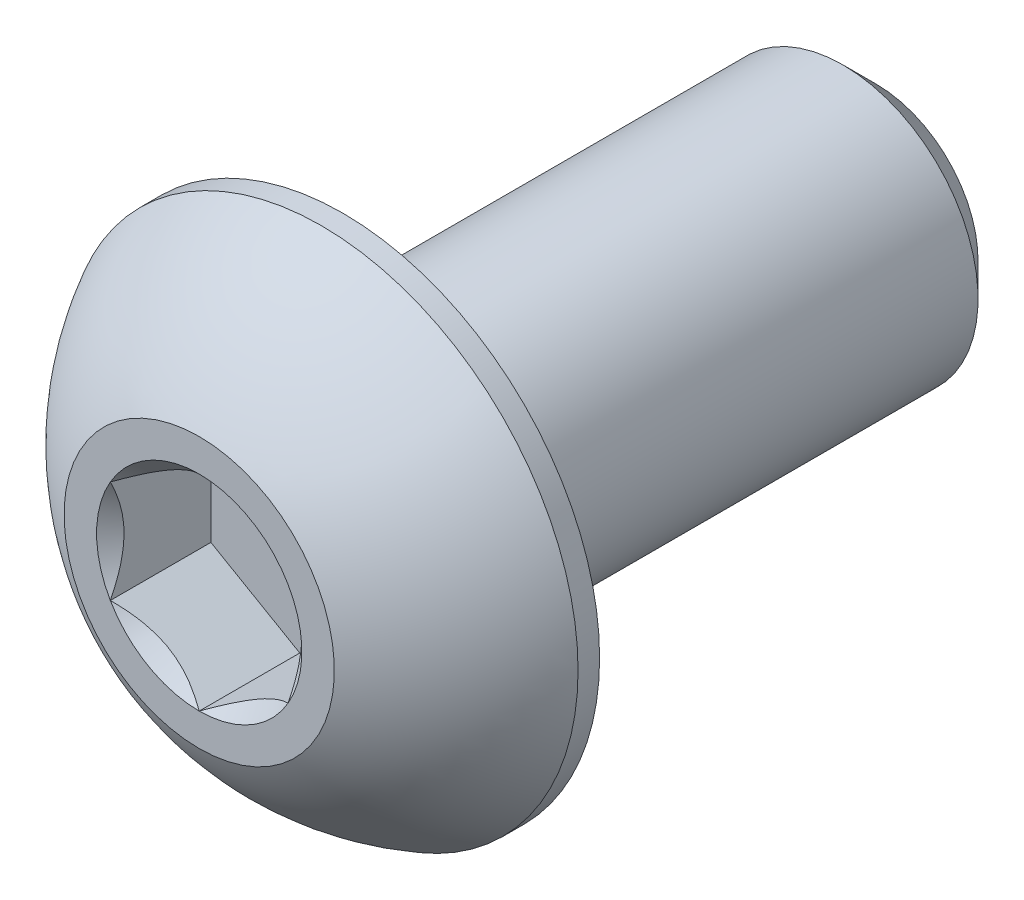
from build123d import *

# Parameters (mm, degrees)
SKETCH1_W          = 9.525
SKETCH1_H          = 2.413
CHAMFER1_SIZE      = 0.5953125
CUT_EXTRUDE2_DEPTH = 1.79578
SKETCH6_R          = 1.833087105
CUT_EXTRUDE3_DEPTH = 1.79578
CUT_EXTRUDE3_TAPER = 45


with BuildPart() as part:
    # Sketch1 → Revolve1 (revolve)
    with BuildSketch(Plane(origin=(0, 0, 0), x_dir=(0, 0, -1), z_dir=(1, 0, 0))):
        with Locations((7.3279, 1.2065)):
            Rectangle(SKETCH1_W, SKETCH1_H)
    revolve(axis=Axis((0, 0, -12.0904), (0, 0, 1)))

    # Chamfer1
    chamfer1_edges = [part.edges().sort_by_distance(p)[0] for p in [
        (0, -2.413, -12.0904),
    ]]
    chamfer(chamfer1_edges, length=CHAMFER1_SIZE)

    # Sketch7 → Revolve2 (revolve)
    with BuildSketch(Plane(origin=(0, 0, 0), x_dir=(0, 0, -1), z_dir=(1, 0, 0))):
        with BuildLine():
            Line((2.18059, 4.5847), (2.5654, 4.5847))
            Line((2.5654, 4.5847), (2.5654, 0))
            Line((2.5654, 0), (0, 0))
            Line((0, 0), (0, 2.413))
            ThreePointArc((0, 2.413), (0.925030326, 3.664791196), (2.18059, 4.5847))
        make_face()
    revolve(axis=Axis((0, 0, 0), (0, 0, -1)))

    # Sketch5 → Cut-Extrude2 (cut)
    with BuildSketch(Plane.XY):
        Polygon((1.5875, -0.916543552), (1.5875, 0.916543552), (0, 1.833087105), (-1.5875, 0.916543552), (-1.5875, -0.916543552), (0, -1.833087105), align=None)
    extrude(amount=-CUT_EXTRUDE2_DEPTH, mode=Mode.SUBTRACT)

    # Sketch6 → Cut-Extrude3 (cut)
    with BuildSketch(Plane.XY):
        Circle(SKETCH6_R)
    extrude(amount=-CUT_EXTRUDE3_DEPTH, taper=CUT_EXTRUDE3_TAPER, mode=Mode.SUBTRACT)


solid = part.part
